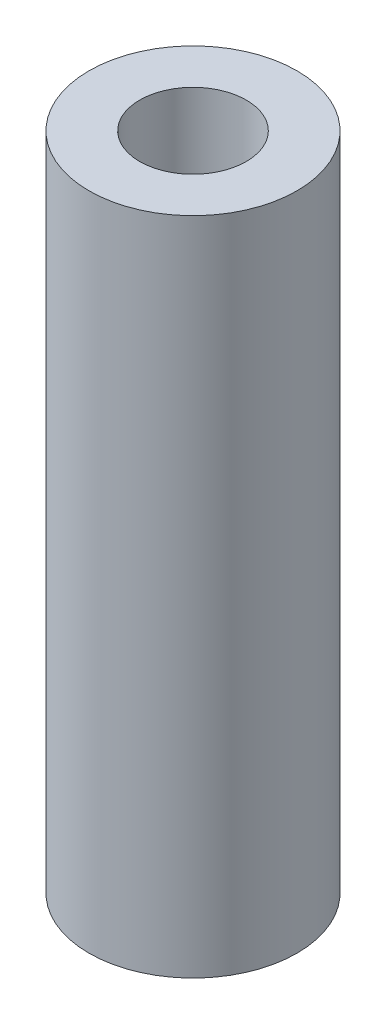
from build123d import *

# Parameters (mm, degrees)
SKETCH1_R           = 4
BOSS_EXTRUDE1_DEPTH = 25.4
SKETCH2_R           = 2.05
CUT_EXTRUDE1_DEPTH  = 26.4


with BuildPart() as part:
    # Sketch1 → Boss-Extrude1 (new body)
    with BuildSketch(Plane(origin=(0, 0, 0), x_dir=(1, 0, 0), z_dir=(0, 1, 0))):
        Circle(SKETCH1_R)
    extrude(amount=BOSS_EXTRUDE1_DEPTH)

    # Sketch2 → Cut-Extrude1 (cut, through all)
    with BuildSketch(Plane(origin=(0, 25.4, 0), x_dir=(1, 0, 0), z_dir=(0, 1, 0))):
        Circle(SKETCH2_R)
    extrude(amount=-CUT_EXTRUDE1_DEPTH, mode=Mode.SUBTRACT)


solid = part.part
